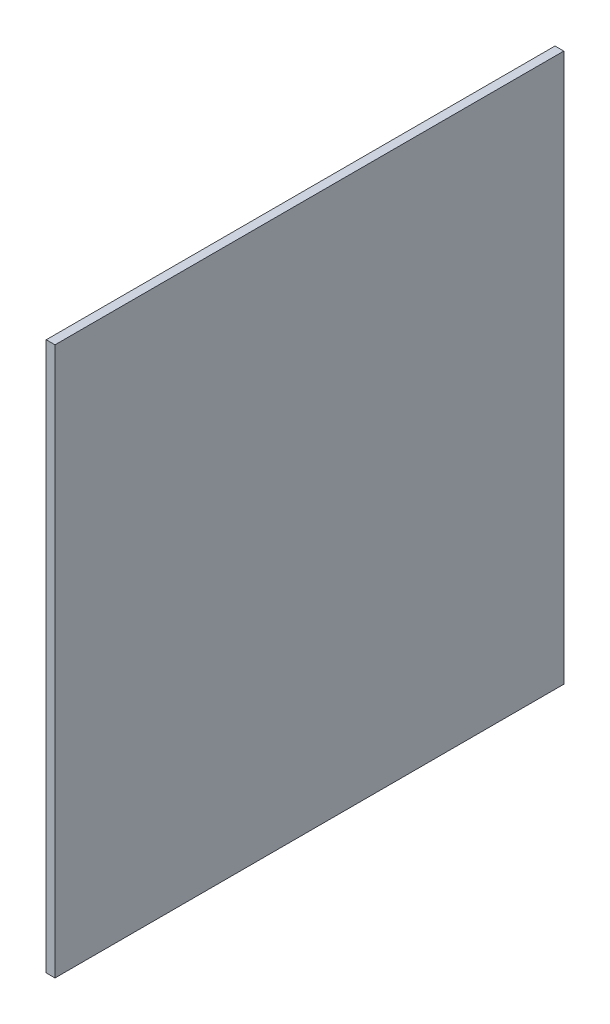
from build123d import *

# Parameters (mm, degrees)
SKETCH1_W           = 117.828
SKETCH1_H           = 127
BOSS_EXTRUDE1_DEPTH = 2.032


with BuildPart() as part:
    # Sketch1 → Boss-Extrude1 (new body)
    with BuildSketch(Plane(origin=(0, 0, 0), x_dir=(0, 0, -1), z_dir=(1, 0, 0))):
        with Locations((63.486, 65.532)):
            Rectangle(SKETCH1_W, SKETCH1_H)
    extrude(amount=BOSS_EXTRUDE1_DEPTH)


solid = part.part
